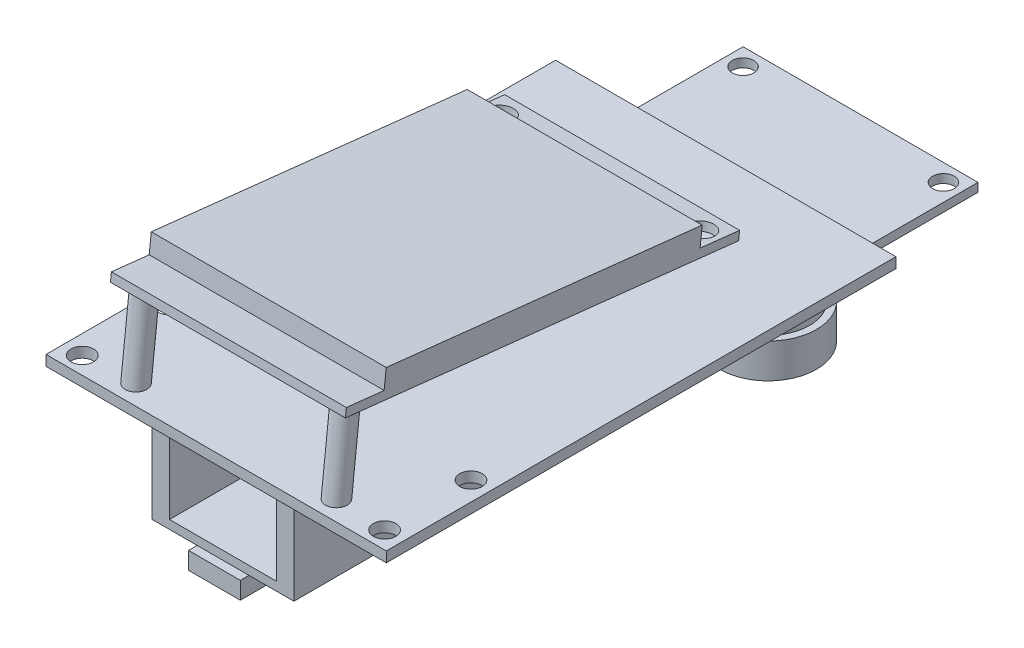
from build123d import *

# Parameters (mm, degrees)
SKETCH1_W                       = 50.038
SKETCH1_H                       = 74.93
SKETCH1_R                       = 1.651
BOSS_EXTRUDE1_DEPTH             = 1.524
BOSS_EXTRUDE2_DEPTH             = 17.272
SKETCH3_R                       = 1.778
CUT_EXTRUDE2_DEPTH              = 1.27
BOSS_EXTRUDE3_REACH             = 48.946
SKETCH4_R                       = 0.254
SKETCH4_R_2                     = 1.5875
SKETCH5_W                       = 2.54
SKETCH5_H                       = 50.8
BOSS_EXTRUDE4_DEPTH             = 11.43
SKETCH6_W                       = 20.828
SKETCH6_H                       = 50.8
BOSS_EXTRUDE5_DEPTH             = 1.27
SKETCH7_R                       = 0.889
BOSS_EXTRUDE6_DEPTH             = 0.635
BOSS_EXTRUDE6_TAPER             = 45
SKETCH7_3_W                     = 7.62
SKETCH7_3_H                     = 6.35
BOSS_EXTRUDE7_DEPTH             = 2.54
BOSS_EXTRUDE8_START             = 2.794
SKETCH9_W                       = 34.544
SKETCH9_H                       = 35.052
BOSS_EXTRUDE8_DEPTH             = 1.27
SKETCH10_W                      = 16.51
SKETCH10_H                      = 16.51
BOSS_EXTRUDE9_DEPTH             = 7.62
SKETCH11_R                      = 7.366
BOSS_EXTRUDE10_DEPTH            = 5.588
SKETCH12_R                      = 6.096
BOSS_EXTRUDE11_DEPTH            = 2.54
SKETCH13_R                      = 7.112
BOSS_EXTRUDE12_DEPTH            = 5.08
SKETCH15_R                      = 1.5875
CUT_EXTRUDE3_DEPTH              = 1.27
SKETCH16_R                      = 0.889
BOSS_EXTRUDE13_DEPTH            = 4.064
SKETCH16_2_R                    = 0.889
BOSS_EXTRUDE14_DEPTH            = 0.635
BOSS_EXTRUDE14_DRAFT            = 45
BOSS_EXTRUDE14_PROFILE_2_DEPTH  = 0.635
BOSS_EXTRUDE14_PROFILE_2_DRAFT  = 45
BOSS_EXTRUDE14_PROFILE_3_DEPTH  = 0.635
BOSS_EXTRUDE14_PROFILE_3_DRAFT  = 45
BOSS_EXTRUDE14_PROFILE_4_DEPTH  = 0.635
BOSS_EXTRUDE14_PROFILE_4_DRAFT  = 45
BOSS_EXTRUDE14_PROFILE_5_DEPTH  = 0.635
BOSS_EXTRUDE14_PROFILE_5_DRAFT  = 45
BOSS_EXTRUDE14_PROFILE_6_DEPTH  = 0.635
BOSS_EXTRUDE14_PROFILE_6_DRAFT  = 45
BOSS_EXTRUDE14_PROFILE_7_DEPTH  = 0.635
BOSS_EXTRUDE14_PROFILE_7_DRAFT  = 45
BOSS_EXTRUDE14_PROFILE_8_DEPTH  = 0.635
BOSS_EXTRUDE14_PROFILE_8_DRAFT  = 45
BOSS_EXTRUDE14_PROFILE_9_DEPTH  = 0.635
BOSS_EXTRUDE14_PROFILE_9_DRAFT  = 45
BOSS_EXTRUDE14_PROFILE_10_DEPTH = 0.635
BOSS_EXTRUDE14_PROFILE_10_DRAFT = 45
BOSS_EXTRUDE14_PROFILE_11_DEPTH = 0.635
BOSS_EXTRUDE14_PROFILE_11_DRAFT = 45
BOSS_EXTRUDE14_PROFILE_12_DEPTH = 0.635
BOSS_EXTRUDE14_PROFILE_12_DRAFT = 45
BOSS_EXTRUDE14_PROFILE_13_DEPTH = 0.635
BOSS_EXTRUDE14_PROFILE_13_DRAFT = 45
BOSS_EXTRUDE14_PROFILE_14_DEPTH = 0.635
BOSS_EXTRUDE14_PROFILE_14_DRAFT = 45
BOSS_EXTRUDE14_PROFILE_15_DEPTH = 0.635
BOSS_EXTRUDE14_PROFILE_15_DRAFT = 45
BOSS_EXTRUDE14_PROFILE_16_DEPTH = 0.635
BOSS_EXTRUDE14_PROFILE_16_DRAFT = 45
BOSS_EXTRUDE14_PROFILE_17_DEPTH = 0.635
BOSS_EXTRUDE14_PROFILE_17_DRAFT = 45
BOSS_EXTRUDE14_PROFILE_18_DEPTH = 0.635
BOSS_EXTRUDE14_PROFILE_18_DRAFT = 45
BOSS_EXTRUDE14_PROFILE_19_DEPTH = 0.635
BOSS_EXTRUDE14_PROFILE_19_DRAFT = 45
BOSS_EXTRUDE14_PROFILE_20_DEPTH = 0.635
BOSS_EXTRUDE14_PROFILE_20_DRAFT = 45


with BuildPart() as part:
    # Sketch1 → Boss-Extrude1 (new body)
    with BuildSketch(Plane(origin=(0, 0, 0), x_dir=(1, 0, 0), z_dir=(0, 1, 0))):
        Rectangle(SKETCH1_W, SKETCH1_H)
        with Locations(Location((22.225, -34.925, 0), (0, 0, 90))):
            Circle(SKETCH1_R, mode=Mode.SUBTRACT)
        with Locations(Location((22.225, -22.225, 0), (0, 0, 90))):
            Circle(SKETCH1_R, mode=Mode.SUBTRACT)
        with Locations(Location((-22.225, -34.925, 0), (0, 0, 90))):
            Circle(SKETCH1_R, mode=Mode.SUBTRACT)
        with Locations(Location((-22.225, -22.225, 0), (0, 0, 90))):
            Circle(SKETCH1_R, mode=Mode.SUBTRACT)
    extrude(amount=BOSS_EXTRUDE1_DEPTH)



with BuildPart() as body_2:
    # Sketch2 → Boss-Extrude2 (new, symmetric)
    with BuildSketch(Plane(origin=(0, 0, 0), x_dir=(0, 0, -1), z_dir=(1, 0, 0))):
        Polygon((-30.038744463, 14.368365618), (16.417917282, 9.266182212), (16.722939116, 12.043482643), (-29.733722629, 17.145666049), align=None)
        Polygon((22.086353712, 7.366), (22.225, 8.628409287), (-35.593345324, 14.978409287), (-35.731991612, 13.716), align=None)
    extrude(amount=BOSS_EXTRUDE2_DEPTH, both=True)

    # Sketch3 → Cut-Extrude2 (cut)
    with BuildSketch(Plane(origin=(0, 10.937382697, -1.201217014), x_dir=(1, 0, 0), z_dir=(0, 0.9940230602749727, -0.1091703056768559))):
        with Locations(Location((14.732, 18.102196435, 0), (0, 0, 270))):
            Circle(SKETCH3_R)
        with Locations(Location((-14.732, 18.102196435, 0), (0, 0, 270))):
            Circle(SKETCH3_R)
    extrude(amount=-CUT_EXTRUDE2_DEPTH, mode=Mode.SUBTRACT)


with BuildPart() as part_1:
    add(part.part)

    add(body_2.part)  # Boss-Extrude3 merges body 2
    # Boss-Extrude3: up to this plane
    boss_extrude3_end = Plane(origin=(0, 1.524, 0), z_dir=(0, 1, 0))
    # Sketch4 → Boss-Extrude3 (add, up to the surface)
    with BuildSketch(Plane(origin=(0, 9.67497341, -1.062570726), x_dir=(1, 0, 0), z_dir=(0, -0.9940230602749727, 0.1091703056768559)), mode=Mode.PRIVATE) as boss_extrude3_sk1:
        with Locations(Location((-0.889, -19.372196435, 0), (0, 0, 270))):
            Circle(SKETCH4_R)
    boss_extrude3_tool1 = split(extrude(boss_extrude3_sk1.sketch, amount=BOSS_EXTRUDE3_REACH, mode=Mode.PRIVATE), bisect_by=boss_extrude3_end, keep=Keep.BOTH, mode=Mode.PRIVATE)
    add(boss_extrude3_tool1.solids().sort_by_distance((-0.889, 7.560105, -20.318981))[0])
    # Sketch4 → Boss-Extrude3 (add, up to the surface)
    with BuildSketch(Plane(origin=(0, 9.67497341, -1.062570726), x_dir=(1, 0, 0), z_dir=(0, -0.9940230602749727, 0.1091703056768559)), mode=Mode.PRIVATE) as boss_extrude3_sk2:
        with Locations(Location((0.889, -19.372196435, 0), (0, 0, 270))):
            Circle(SKETCH4_R)
    boss_extrude3_tool2 = split(extrude(boss_extrude3_sk2.sketch, amount=BOSS_EXTRUDE3_REACH, mode=Mode.PRIVATE), bisect_by=boss_extrude3_end, keep=Keep.BOTH, mode=Mode.PRIVATE)
    add(boss_extrude3_tool2.solids().sort_by_distance((0.889, 7.560105, -20.318981))[0])
    # Sketch4 → Boss-Extrude3 (add, up to the surface)
    with BuildSketch(Plane(origin=(0, 9.67497341, -1.062570726), x_dir=(1, 0, 0), z_dir=(0, -0.9940230602749727, 0.1091703056768559)), mode=Mode.PRIVATE) as boss_extrude3_sk3:
        with Locations(Location((-2.667, -19.372196435, 0), (0, 0, 270))):
            Circle(SKETCH4_R)
    boss_extrude3_tool3 = split(extrude(boss_extrude3_sk3.sketch, amount=BOSS_EXTRUDE3_REACH, mode=Mode.PRIVATE), bisect_by=boss_extrude3_end, keep=Keep.BOTH, mode=Mode.PRIVATE)
    add(boss_extrude3_tool3.solids().sort_by_distance((-2.667, 7.560105, -20.318981))[0])
    # Sketch4 → Boss-Extrude3 (add, up to the surface)
    with BuildSketch(Plane(origin=(0, 9.67497341, -1.062570726), x_dir=(1, 0, 0), z_dir=(0, -0.9940230602749727, 0.1091703056768559)), mode=Mode.PRIVATE) as boss_extrude3_sk4:
        with Locations(Location((-4.445, -19.372196435, 0), (0, 0, 270))):
            Circle(SKETCH4_R)
    boss_extrude3_tool4 = split(extrude(boss_extrude3_sk4.sketch, amount=BOSS_EXTRUDE3_REACH, mode=Mode.PRIVATE), bisect_by=boss_extrude3_end, keep=Keep.BOTH, mode=Mode.PRIVATE)
    add(boss_extrude3_tool4.solids().sort_by_distance((-4.445, 7.560105, -20.318981))[0])
    # Sketch4 → Boss-Extrude3 (add, up to the surface)
    with BuildSketch(Plane(origin=(0, 9.67497341, -1.062570726), x_dir=(1, 0, 0), z_dir=(0, -0.9940230602749727, 0.1091703056768559)), mode=Mode.PRIVATE) as boss_extrude3_sk5:
        with Locations(Location((-6.223, -19.372196435, 0), (0, 0, 270))):
            Circle(SKETCH4_R)
    boss_extrude3_tool5 = split(extrude(boss_extrude3_sk5.sketch, amount=BOSS_EXTRUDE3_REACH, mode=Mode.PRIVATE), bisect_by=boss_extrude3_end, keep=Keep.BOTH, mode=Mode.PRIVATE)
    add(boss_extrude3_tool5.solids().sort_by_distance((-6.223, 7.560105, -20.318981))[0])
    # Sketch4 → Boss-Extrude3 (add, up to the surface)
    with BuildSketch(Plane(origin=(0, 9.67497341, -1.062570726), x_dir=(1, 0, 0), z_dir=(0, -0.9940230602749727, 0.1091703056768559)), mode=Mode.PRIVATE) as boss_extrude3_sk6:
        with Locations(Location((2.667, -19.372196435, 0), (0, 0, 270))):
            Circle(SKETCH4_R)
    boss_extrude3_tool6 = split(extrude(boss_extrude3_sk6.sketch, amount=BOSS_EXTRUDE3_REACH, mode=Mode.PRIVATE), bisect_by=boss_extrude3_end, keep=Keep.BOTH, mode=Mode.PRIVATE)
    add(boss_extrude3_tool6.solids().sort_by_distance((2.667, 7.560105, -20.318981))[0])
    # Sketch4 → Boss-Extrude3 (add, up to the surface)
    with BuildSketch(Plane(origin=(0, 9.67497341, -1.062570726), x_dir=(1, 0, 0), z_dir=(0, -0.9940230602749727, 0.1091703056768559)), mode=Mode.PRIVATE) as boss_extrude3_sk7:
        with Locations(Location((4.445, -19.372196435, 0), (0, 0, 270))):
            Circle(SKETCH4_R)
    boss_extrude3_tool7 = split(extrude(boss_extrude3_sk7.sketch, amount=BOSS_EXTRUDE3_REACH, mode=Mode.PRIVATE), bisect_by=boss_extrude3_end, keep=Keep.BOTH, mode=Mode.PRIVATE)
    add(boss_extrude3_tool7.solids().sort_by_distance((4.445, 7.560105, -20.318981))[0])
    # Sketch4 → Boss-Extrude3 (add, up to the surface)
    with BuildSketch(Plane(origin=(0, 9.67497341, -1.062570726), x_dir=(1, 0, 0), z_dir=(0, -0.9940230602749727, 0.1091703056768559)), mode=Mode.PRIVATE) as boss_extrude3_sk8:
        with Locations(Location((6.223, -19.372196435, 0), (0, 0, 270))):
            Circle(SKETCH4_R)
    boss_extrude3_tool8 = split(extrude(boss_extrude3_sk8.sketch, amount=BOSS_EXTRUDE3_REACH, mode=Mode.PRIVATE), bisect_by=boss_extrude3_end, keep=Keep.BOTH, mode=Mode.PRIVATE)
    add(boss_extrude3_tool8.solids().sort_by_distance((6.223, 7.560105, -20.318981))[0])
    # Sketch4 → Boss-Extrude3 (add, up to the surface)
    with BuildSketch(Plane(origin=(0, 9.67497341, -1.062570726), x_dir=(1, 0, 0), z_dir=(0, -0.9940230602749727, 0.1091703056768559)), mode=Mode.PRIVATE) as boss_extrude3_sk9:
        with Locations(Location((14.732, 34.475803565, 0), (0, 0, 270))):
            Circle(SKETCH4_R_2)
    boss_extrude3_tool9 = split(extrude(boss_extrude3_sk9.sketch, amount=BOSS_EXTRUDE3_REACH, mode=Mode.PRIVATE), bisect_by=boss_extrude3_end, keep=Keep.BOTH, mode=Mode.PRIVATE)
    add(boss_extrude3_tool9.solids().sort_by_distance((14.732, 13.438707, 33.207173))[0])
    # Sketch4 → Boss-Extrude3 (add, up to the surface)
    with BuildSketch(Plane(origin=(0, 9.67497341, -1.062570726), x_dir=(1, 0, 0), z_dir=(0, -0.9940230602749727, 0.1091703056768559)), mode=Mode.PRIVATE) as boss_extrude3_sk10:
        with Locations(Location((-14.732, 34.475803565, 0), (0, 0, 90))):
            Circle(SKETCH4_R_2)
    boss_extrude3_tool10 = split(extrude(boss_extrude3_sk10.sketch, amount=BOSS_EXTRUDE3_REACH, mode=Mode.PRIVATE), bisect_by=boss_extrude3_end, keep=Keep.BOTH, mode=Mode.PRIVATE)
    add(boss_extrude3_tool10.solids().sort_by_distance((-14.732, 13.438707, 33.207173))[0])

    # Sketch5 → Boss-Extrude4 (add)
    with BuildSketch(Plane.XZ):
        with Locations((9.144, 11.049)):
            Rectangle(SKETCH5_W, SKETCH5_H)
        with Locations((-9.144, 11.049)):
            Rectangle(SKETCH5_W, SKETCH5_H)
    extrude(amount=BOSS_EXTRUDE4_DEPTH)

    # Sketch6 → Boss-Extrude5 (add)
    with BuildSketch(Plane.XZ.offset(11.43)):
        with Locations((0, 11.049)):
            Rectangle(SKETCH6_W, SKETCH6_H)
    extrude(amount=BOSS_EXTRUDE5_DEPTH)

    # Sketch7 → Boss-Extrude6 (add)
    with BuildSketch(Plane.XZ.offset(12.7)):
        with Locations((-9.144, 32.639)):
            Circle(SKETCH7_R)
        with Locations((-9.144, 30.099)):
            Circle(SKETCH7_R)
        with Locations((-9.144, 25.019)):
            Circle(SKETCH7_R)
        with Locations((-9.144, 22.479)):
            Circle(SKETCH7_R)
        with Locations((-9.144, 19.939)):
            Circle(SKETCH7_R)
        with Locations((-9.144, 14.859)):
            Circle(SKETCH7_R)
        with Locations((-9.144, 4.699)):
            Circle(SKETCH7_R)
        with Locations((-9.144, 2.159)):
            Circle(SKETCH7_R)
        with Locations((-9.144, -8.001)):
            Circle(SKETCH7_R)
        with Locations((-9.144, -10.541)):
            Circle(SKETCH7_R)
        with Locations((-9.144, -13.081)):
            Circle(SKETCH7_R)
        with Locations((9.144, -10.541)):
            Circle(SKETCH7_R)
        with Locations((9.144, -2.921)):
            Circle(SKETCH7_R)
        with Locations((9.144, 2.159)):
            Circle(SKETCH7_R)
        with Locations((9.144, 4.699)):
            Circle(SKETCH7_R)
        with Locations((9.144, 7.239)):
            Circle(SKETCH7_R)
        with Locations((9.144, 17.399)):
            Circle(SKETCH7_R)
        with Locations((9.144, 19.939)):
            Circle(SKETCH7_R)
        with Locations((9.144, 35.179)):
            Circle(SKETCH7_R)
        with Locations((-9.144, 35.179)):
            Circle(SKETCH7_R)
        with Locations((-9.144, 27.559)):
            Circle(SKETCH7_R)
        with Locations((-9.144, 17.399)):
            Circle(SKETCH7_R)
        with Locations((-9.144, 12.319)):
            Circle(SKETCH7_R)
        with Locations((-9.144, 9.779)):
            Circle(SKETCH7_R)
        with Locations((-9.144, 7.239)):
            Circle(SKETCH7_R)
        with Locations((-9.144, -0.381)):
            Circle(SKETCH7_R)
        with Locations((-9.144, -2.921)):
            Circle(SKETCH7_R)
        with Locations((-9.144, -5.461)):
            Circle(SKETCH7_R)
        with Locations((9.144, -13.081)):
            Circle(SKETCH7_R)
        with Locations((9.144, -8.001)):
            Circle(SKETCH7_R)
        with Locations((9.144, -5.461)):
            Circle(SKETCH7_R)
        with Locations((9.144, -0.381)):
            Circle(SKETCH7_R)
        with Locations((9.144, 9.779)):
            Circle(SKETCH7_R)
        with Locations((9.144, 12.319)):
            Circle(SKETCH7_R)
        with Locations((9.144, 14.859)):
            Circle(SKETCH7_R)
        with Locations((9.144, 22.479)):
            Circle(SKETCH7_R)
        with Locations((9.144, 25.019)):
            Circle(SKETCH7_R)
        with Locations((9.144, 27.559)):
            Circle(SKETCH7_R)
        with Locations((9.144, 30.099)):
            Circle(SKETCH7_R)
        with Locations((9.144, 32.639)):
            Circle(SKETCH7_R)
    extrude(amount=BOSS_EXTRUDE6_DEPTH, taper=BOSS_EXTRUDE6_TAPER)

    # Sketch7_3 → Boss-Extrude7 (add)
    with BuildSketch(Plane.XZ.offset(12.7)):
        with Locations((0, 34.544)):
            Rectangle(SKETCH7_3_W, SKETCH7_3_H)
    extrude(amount=BOSS_EXTRUDE7_DEPTH)


with BuildPart() as body_2_2:
    # Sketch9 → Boss-Extrude8 (new body)
    with BuildSketch(Plane.XZ.offset(BOSS_EXTRUDE8_START)):
        with Locations((0, -39.751)):
            Rectangle(SKETCH9_W, SKETCH9_H)
    extrude(amount=BOSS_EXTRUDE8_DEPTH)

    # Sketch10 → Boss-Extrude9 (add)
    with BuildSketch(Plane.XZ.offset(4.064)):
        with BuildLine():
            Line((-9.779, -45.72), (-8.255, -45.72))
            Line((-8.255, -45.72), (-8.255, -41.656))
            Line((-8.255, -41.656), (-9.779, -41.656))
            ThreePointArc((-9.779, -41.656), (-11.811, -43.688), (-9.779, -45.72))
        make_face()
        with Locations((0, -43.688)):
            Rectangle(SKETCH10_W, SKETCH10_H)
        with BuildLine():
            Line((8.255, -41.656), (8.255, -45.72))
            Line((8.255, -45.72), (9.779, -45.72))
            ThreePointArc((9.779, -45.72), (11.811, -43.688), (9.779, -41.656))
            Line((9.779, -41.656), (8.255, -41.656))
        make_face()
    extrude(amount=BOSS_EXTRUDE9_DEPTH)

    # Sketch11 → Boss-Extrude10 (add)
    with BuildSketch(Plane.XZ.offset(11.684)):
        with Locations(Location((0, -43.688, 0), (0, 0, 270))):
            Circle(SKETCH11_R)
    extrude(amount=BOSS_EXTRUDE10_DEPTH)

    # Sketch12 → Boss-Extrude11 (add)
    with BuildSketch(Plane.XZ.offset(17.272)):
        with Locations(Location((0, -43.688, 0), (0, 0, 270))):
            Circle(SKETCH12_R)
    extrude(amount=BOSS_EXTRUDE11_DEPTH)

    # Sketch13 → Boss-Extrude12 (add)
    with BuildSketch(Plane.XZ.offset(19.812)):
        with Locations(Location((0, -43.688, 0), (0, 0, 270))):
            Circle(SKETCH13_R)
    extrude(amount=BOSS_EXTRUDE12_DEPTH)

    # Sketch14 → Cut-Revolve1 (revolve, cut)
    with BuildSketch(Plane(origin=(0, 0, 0), x_dir=(0, 0, -1), z_dir=(1, 0, 0)), mode=Mode.PRIVATE) as cut_revolve1_sk:
        with BuildLine():
            Line((50.54454245, -24.892), (49.444690187, -24.257))
            add(Edge.make_bspline(
                [(43.688, -24.765), (46.588759362, -24.765), (49.444690187, -24.257)],
                knots=[0, 0, 0, 1, 1, 1], degree=2))
            Line((43.688, -24.765), (43.688, -27.265018721))
            Line((43.688, -27.265018721), (50.54454245, -27.265018721))
            Line((50.54454245, -27.265018721), (50.54454245, -24.892))
        make_face()
    revolve(cut_revolve1_sk.sketch.rotate(Axis((0, -19.812, -43.688), (0, -1, 0)), 180), axis=Axis((0, -19.812, -43.688), (0, -1, 0)), mode=Mode.SUBTRACT)

    # Sketch15 → Cut-Extrude3 (cut)
    with BuildSketch(Plane.XZ.offset(4.064)):
        with Locations(Location((-14.732, -24.765, 0), (0, 0, 270))):
            Circle(SKETCH15_R)
        with Locations(Location((14.732, -24.765, 0), (0, 0, 90))):
            Circle(SKETCH15_R)
        with Locations(Location((14.732, -54.737, 0), (0, 0, 270))):
            Circle(SKETCH15_R)
        with Locations(Location((-14.732, -54.737, 0), (0, 0, 90))):
            Circle(SKETCH15_R)
    extrude(amount=-CUT_EXTRUDE3_DEPTH, mode=Mode.SUBTRACT)

    # Sketch16 → Boss-Extrude13 (add)
    with BuildSketch(Plane.XZ.offset(4.064)):
        with Locations(Location((11.43, -27.305, 0), (0, 0, 90))):
            Circle(SKETCH16_R)
        with Locations(Location((8.89, -27.305, 0), (0, 0, 90))):
            Circle(SKETCH16_R)
        with Locations(Location((6.35, -27.305, 0), (0, 0, 90))):
            Circle(SKETCH16_R)
        with Locations(Location((3.81, -27.305, 0), (0, 0, 90))):
            Circle(SKETCH16_R)
        with Locations(Location((1.27, -27.305, 0), (0, 0, 90))):
            Circle(SKETCH16_R)
        with Locations(Location((-1.27, -27.305, 0), (0, 0, 90))):
            Circle(SKETCH16_R)
        with Locations(Location((-3.81, -27.305, 0), (0, 0, 90))):
            Circle(SKETCH16_R)
        with Locations(Location((-6.35, -27.305, 0), (0, 0, 90))):
            Circle(SKETCH16_R)
        with Locations(Location((-8.89, -27.305, 0), (0, 0, 90))):
            Circle(SKETCH16_R)
        with Locations(Location((-11.43, -27.305, 0), (0, 0, 90))):
            Circle(SKETCH16_R)
        with Locations(Location((8.89, -29.845, 0), (0, 0, 90))):
            Circle(SKETCH16_R)
        with Locations(Location((6.35, -29.845, 0), (0, 0, 90))):
            Circle(SKETCH16_R)
        with Locations(Location((3.81, -29.845, 0), (0, 0, 90))):
            Circle(SKETCH16_R)
        with Locations(Location((1.27, -29.845, 0), (0, 0, 90))):
            Circle(SKETCH16_R)
        with Locations(Location((-1.27, -29.845, 0), (0, 0, 90))):
            Circle(SKETCH16_R)
        with Locations(Location((-3.81, -29.845, 0), (0, 0, 90))):
            Circle(SKETCH16_R)
        with Locations(Location((-6.35, -29.845, 0), (0, 0, 90))):
            Circle(SKETCH16_R)
        with Locations(Location((-8.89, -29.845, 0), (0, 0, 90))):
            Circle(SKETCH16_R)
        with Locations(Location((-11.43, -29.845, 0), (0, 0, 90))):
            Circle(SKETCH16_R)
        with Locations(Location((11.43, -29.845, 0), (0, 0, 90))):
            Circle(SKETCH16_R)
    extrude(amount=-BOSS_EXTRUDE13_DEPTH)


with BuildPart() as boss_extrude14_tool:
    # Sketch16_2 → Boss-Extrude14 (with draft: the straight prism first)
    with BuildSketch(Plane.XZ.offset(4.064)):
        with Locations(Location((-11.43, -29.845, 0), (0, 0, 90))):
            Circle(SKETCH16_2_R)
    extrude(amount=BOSS_EXTRUDE14_DEPTH)
    # Boss-Extrude14: the draft: its side faces are tilted about the plane it starts from
    boss_extrude14_sides = [boss_extrude14_tool.faces().sort_by_distance(p)[0] for p in [
        (-11.43, -4.3815, -30.734),
    ]]
    draft(boss_extrude14_sides, Plane.XZ.offset(4.064), BOSS_EXTRUDE14_DRAFT)


with BuildPart() as part_2:
    add(part_1.part)

    # Boss-Extrude14: add boss_extrude14_tool
    add(boss_extrude14_tool.part)

    add(body_2_2.part)  # Boss-Extrude14 merges body 2 2


with BuildPart() as boss_extrude14_profile_2_tool:
    # Sketch16_2 → Boss-Extrude14 profile 2 (with draft: the straight prism first)
    with BuildSketch(Plane.XZ.offset(4.064)):
        with Locations(Location((-8.89, -29.845, 0), (0, 0, 90))):
            Circle(SKETCH16_2_R)
    extrude(amount=BOSS_EXTRUDE14_PROFILE_2_DEPTH)
    # Boss-Extrude14 profile 2: the draft: its side faces are tilted about the plane it starts from
    boss_extrude14_profile_2_sides = [boss_extrude14_profile_2_tool.faces().sort_by_distance(p)[0] for p in [
        (-8.89, -4.3815, -30.734),
    ]]
    draft(boss_extrude14_profile_2_sides, Plane.XZ.offset(4.064), BOSS_EXTRUDE14_PROFILE_2_DRAFT)


with BuildPart() as part_3:
    add(part_2.part)

    # Boss-Extrude14 profile 2: add boss_extrude14_profile_2_tool
    add(boss_extrude14_profile_2_tool.part)


with BuildPart() as boss_extrude14_profile_3_tool:
    # Sketch16_2 → Boss-Extrude14 profile 3 (with draft: the straight prism first)
    with BuildSketch(Plane.XZ.offset(4.064)):
        with Locations(Location((-8.89, -27.305, 0), (0, 0, 90))):
            Circle(SKETCH16_2_R)
    extrude(amount=BOSS_EXTRUDE14_PROFILE_3_DEPTH)
    # Boss-Extrude14 profile 3: the draft: its side faces are tilted about the plane it starts from
    boss_extrude14_profile_3_sides = [boss_extrude14_profile_3_tool.faces().sort_by_distance(p)[0] for p in [
        (-8.89, -4.3815, -28.194),
    ]]
    draft(boss_extrude14_profile_3_sides, Plane.XZ.offset(4.064), BOSS_EXTRUDE14_PROFILE_3_DRAFT)


with BuildPart() as part_4:
    add(part_3.part)

    # Boss-Extrude14 profile 3: add boss_extrude14_profile_3_tool
    add(boss_extrude14_profile_3_tool.part)


with BuildPart() as boss_extrude14_profile_4_tool:
    # Sketch16_2 → Boss-Extrude14 profile 4 (with draft: the straight prism first)
    with BuildSketch(Plane.XZ.offset(4.064)):
        with Locations(Location((-6.35, -27.305, 0), (0, 0, 90))):
            Circle(SKETCH16_2_R)
    extrude(amount=BOSS_EXTRUDE14_PROFILE_4_DEPTH)
    # Boss-Extrude14 profile 4: the draft: its side faces are tilted about the plane it starts from
    boss_extrude14_profile_4_sides = [boss_extrude14_profile_4_tool.faces().sort_by_distance(p)[0] for p in [
        (-6.35, -4.3815, -28.194),
    ]]
    draft(boss_extrude14_profile_4_sides, Plane.XZ.offset(4.064), BOSS_EXTRUDE14_PROFILE_4_DRAFT)


with BuildPart() as part_5:
    add(part_4.part)

    # Boss-Extrude14 profile 4: add boss_extrude14_profile_4_tool
    add(boss_extrude14_profile_4_tool.part)


with BuildPart() as boss_extrude14_profile_5_tool:
    # Sketch16_2 → Boss-Extrude14 profile 5 (with draft: the straight prism first)
    with BuildSketch(Plane.XZ.offset(4.064)):
        with Locations(Location((-6.35, -29.845, 0), (0, 0, 90))):
            Circle(SKETCH16_2_R)
    extrude(amount=BOSS_EXTRUDE14_PROFILE_5_DEPTH)
    # Boss-Extrude14 profile 5: the draft: its side faces are tilted about the plane it starts from
    boss_extrude14_profile_5_sides = [boss_extrude14_profile_5_tool.faces().sort_by_distance(p)[0] for p in [
        (-6.35, -4.3815, -30.734),
    ]]
    draft(boss_extrude14_profile_5_sides, Plane.XZ.offset(4.064), BOSS_EXTRUDE14_PROFILE_5_DRAFT)


with BuildPart() as part_6:
    add(part_5.part)

    # Boss-Extrude14 profile 5: add boss_extrude14_profile_5_tool
    add(boss_extrude14_profile_5_tool.part)


with BuildPart() as boss_extrude14_profile_6_tool:
    # Sketch16_2 → Boss-Extrude14 profile 6 (with draft: the straight prism first)
    with BuildSketch(Plane.XZ.offset(4.064)):
        with Locations(Location((-3.81, -29.845, 0), (0, 0, 90))):
            Circle(SKETCH16_2_R)
    extrude(amount=BOSS_EXTRUDE14_PROFILE_6_DEPTH)
    # Boss-Extrude14 profile 6: the draft: its side faces are tilted about the plane it starts from
    boss_extrude14_profile_6_sides = [boss_extrude14_profile_6_tool.faces().sort_by_distance(p)[0] for p in [
        (-3.81, -4.3815, -30.734),
    ]]
    draft(boss_extrude14_profile_6_sides, Plane.XZ.offset(4.064), BOSS_EXTRUDE14_PROFILE_6_DRAFT)


with BuildPart() as part_7:
    add(part_6.part)

    # Boss-Extrude14 profile 6: add boss_extrude14_profile_6_tool
    add(boss_extrude14_profile_6_tool.part)


with BuildPart() as boss_extrude14_profile_7_tool:
    # Sketch16_2 → Boss-Extrude14 profile 7 (with draft: the straight prism first)
    with BuildSketch(Plane.XZ.offset(4.064)):
        with Locations(Location((-3.81, -27.305, 0), (0, 0, 90))):
            Circle(SKETCH16_2_R)
    extrude(amount=BOSS_EXTRUDE14_PROFILE_7_DEPTH)
    # Boss-Extrude14 profile 7: the draft: its side faces are tilted about the plane it starts from
    boss_extrude14_profile_7_sides = [boss_extrude14_profile_7_tool.faces().sort_by_distance(p)[0] for p in [
        (-3.81, -4.3815, -28.194),
    ]]
    draft(boss_extrude14_profile_7_sides, Plane.XZ.offset(4.064), BOSS_EXTRUDE14_PROFILE_7_DRAFT)


with BuildPart() as part_8:
    add(part_7.part)

    # Boss-Extrude14 profile 7: add boss_extrude14_profile_7_tool
    add(boss_extrude14_profile_7_tool.part)


with BuildPart() as boss_extrude14_profile_8_tool:
    # Sketch16_2 → Boss-Extrude14 profile 8 (with draft: the straight prism first)
    with BuildSketch(Plane.XZ.offset(4.064)):
        with Locations(Location((-1.27, -27.305, 0), (0, 0, 90))):
            Circle(SKETCH16_2_R)
    extrude(amount=BOSS_EXTRUDE14_PROFILE_8_DEPTH)
    # Boss-Extrude14 profile 8: the draft: its side faces are tilted about the plane it starts from
    boss_extrude14_profile_8_sides = [boss_extrude14_profile_8_tool.faces().sort_by_distance(p)[0] for p in [
        (-1.27, -4.3815, -28.194),
    ]]
    draft(boss_extrude14_profile_8_sides, Plane.XZ.offset(4.064), BOSS_EXTRUDE14_PROFILE_8_DRAFT)


with BuildPart() as part_9:
    add(part_8.part)

    # Boss-Extrude14 profile 8: add boss_extrude14_profile_8_tool
    add(boss_extrude14_profile_8_tool.part)


with BuildPart() as boss_extrude14_profile_9_tool:
    # Sketch16_2 → Boss-Extrude14 profile 9 (with draft: the straight prism first)
    with BuildSketch(Plane.XZ.offset(4.064)):
        with Locations(Location((-1.27, -29.845, 0), (0, 0, 90))):
            Circle(SKETCH16_2_R)
    extrude(amount=BOSS_EXTRUDE14_PROFILE_9_DEPTH)
    # Boss-Extrude14 profile 9: the draft: its side faces are tilted about the plane it starts from
    boss_extrude14_profile_9_sides = [boss_extrude14_profile_9_tool.faces().sort_by_distance(p)[0] for p in [
        (-1.27, -4.3815, -30.734),
    ]]
    draft(boss_extrude14_profile_9_sides, Plane.XZ.offset(4.064), BOSS_EXTRUDE14_PROFILE_9_DRAFT)


with BuildPart() as part_10:
    add(part_9.part)

    # Boss-Extrude14 profile 9: add boss_extrude14_profile_9_tool
    add(boss_extrude14_profile_9_tool.part)


with BuildPart() as boss_extrude14_profile_10_tool:
    # Sketch16_2 → Boss-Extrude14 profile 10 (with draft: the straight prism first)
    with BuildSketch(Plane.XZ.offset(4.064)):
        with Locations(Location((1.27, -29.845, 0), (0, 0, 90))):
            Circle(SKETCH16_2_R)
    extrude(amount=BOSS_EXTRUDE14_PROFILE_10_DEPTH)
    # Boss-Extrude14 profile 10: the draft: its side faces are tilted about the plane it starts from
    boss_extrude14_profile_10_sides = [boss_extrude14_profile_10_tool.faces().sort_by_distance(p)[0] for p in [
        (1.27, -4.3815, -30.734),
    ]]
    draft(boss_extrude14_profile_10_sides, Plane.XZ.offset(4.064), BOSS_EXTRUDE14_PROFILE_10_DRAFT)


with BuildPart() as part_11:
    add(part_10.part)

    # Boss-Extrude14 profile 10: add boss_extrude14_profile_10_tool
    add(boss_extrude14_profile_10_tool.part)


with BuildPart() as boss_extrude14_profile_11_tool:
    # Sketch16_2 → Boss-Extrude14 profile 11 (with draft: the straight prism first)
    with BuildSketch(Plane.XZ.offset(4.064)):
        with Locations(Location((1.27, -27.305, 0), (0, 0, 90))):
            Circle(SKETCH16_2_R)
    extrude(amount=BOSS_EXTRUDE14_PROFILE_11_DEPTH)
    # Boss-Extrude14 profile 11: the draft: its side faces are tilted about the plane it starts from
    boss_extrude14_profile_11_sides = [boss_extrude14_profile_11_tool.faces().sort_by_distance(p)[0] for p in [
        (1.27, -4.3815, -28.194),
    ]]
    draft(boss_extrude14_profile_11_sides, Plane.XZ.offset(4.064), BOSS_EXTRUDE14_PROFILE_11_DRAFT)


with BuildPart() as part_12:
    add(part_11.part)

    # Boss-Extrude14 profile 11: add boss_extrude14_profile_11_tool
    add(boss_extrude14_profile_11_tool.part)


with BuildPart() as boss_extrude14_profile_12_tool:
    # Sketch16_2 → Boss-Extrude14 profile 12 (with draft: the straight prism first)
    with BuildSketch(Plane.XZ.offset(4.064)):
        with Locations(Location((3.81, -29.845, 0), (0, 0, 90))):
            Circle(SKETCH16_2_R)
    extrude(amount=BOSS_EXTRUDE14_PROFILE_12_DEPTH)
    # Boss-Extrude14 profile 12: the draft: its side faces are tilted about the plane it starts from
    boss_extrude14_profile_12_sides = [boss_extrude14_profile_12_tool.faces().sort_by_distance(p)[0] for p in [
        (3.81, -4.3815, -30.734),
    ]]
    draft(boss_extrude14_profile_12_sides, Plane.XZ.offset(4.064), BOSS_EXTRUDE14_PROFILE_12_DRAFT)


with BuildPart() as part_13:
    add(part_12.part)

    # Boss-Extrude14 profile 12: add boss_extrude14_profile_12_tool
    add(boss_extrude14_profile_12_tool.part)


with BuildPart() as boss_extrude14_profile_13_tool:
    # Sketch16_2 → Boss-Extrude14 profile 13 (with draft: the straight prism first)
    with BuildSketch(Plane.XZ.offset(4.064)):
        with Locations(Location((3.81, -27.305, 0), (0, 0, 90))):
            Circle(SKETCH16_2_R)
    extrude(amount=BOSS_EXTRUDE14_PROFILE_13_DEPTH)
    # Boss-Extrude14 profile 13: the draft: its side faces are tilted about the plane it starts from
    boss_extrude14_profile_13_sides = [boss_extrude14_profile_13_tool.faces().sort_by_distance(p)[0] for p in [
        (3.81, -4.3815, -28.194),
    ]]
    draft(boss_extrude14_profile_13_sides, Plane.XZ.offset(4.064), BOSS_EXTRUDE14_PROFILE_13_DRAFT)


with BuildPart() as part_14:
    add(part_13.part)

    # Boss-Extrude14 profile 13: add boss_extrude14_profile_13_tool
    add(boss_extrude14_profile_13_tool.part)


with BuildPart() as boss_extrude14_profile_14_tool:
    # Sketch16_2 → Boss-Extrude14 profile 14 (with draft: the straight prism first)
    with BuildSketch(Plane.XZ.offset(4.064)):
        with Locations(Location((6.35, -29.845, 0), (0, 0, 90))):
            Circle(SKETCH16_2_R)
    extrude(amount=BOSS_EXTRUDE14_PROFILE_14_DEPTH)
    # Boss-Extrude14 profile 14: the draft: its side faces are tilted about the plane it starts from
    boss_extrude14_profile_14_sides = [boss_extrude14_profile_14_tool.faces().sort_by_distance(p)[0] for p in [
        (6.35, -4.3815, -30.734),
    ]]
    draft(boss_extrude14_profile_14_sides, Plane.XZ.offset(4.064), BOSS_EXTRUDE14_PROFILE_14_DRAFT)


with BuildPart() as part_15:
    add(part_14.part)

    # Boss-Extrude14 profile 14: add boss_extrude14_profile_14_tool
    add(boss_extrude14_profile_14_tool.part)


with BuildPart() as boss_extrude14_profile_15_tool:
    # Sketch16_2 → Boss-Extrude14 profile 15 (with draft: the straight prism first)
    with BuildSketch(Plane.XZ.offset(4.064)):
        with Locations(Location((6.35, -27.305, 0), (0, 0, 90))):
            Circle(SKETCH16_2_R)
    extrude(amount=BOSS_EXTRUDE14_PROFILE_15_DEPTH)
    # Boss-Extrude14 profile 15: the draft: its side faces are tilted about the plane it starts from
    boss_extrude14_profile_15_sides = [boss_extrude14_profile_15_tool.faces().sort_by_distance(p)[0] for p in [
        (6.35, -4.3815, -28.194),
    ]]
    draft(boss_extrude14_profile_15_sides, Plane.XZ.offset(4.064), BOSS_EXTRUDE14_PROFILE_15_DRAFT)


with BuildPart() as part_16:
    add(part_15.part)

    # Boss-Extrude14 profile 15: add boss_extrude14_profile_15_tool
    add(boss_extrude14_profile_15_tool.part)


with BuildPart() as boss_extrude14_profile_16_tool:
    # Sketch16_2 → Boss-Extrude14 profile 16 (with draft: the straight prism first)
    with BuildSketch(Plane.XZ.offset(4.064)):
        with Locations(Location((8.89, -29.845, 0), (0, 0, 90))):
            Circle(SKETCH16_2_R)
    extrude(amount=BOSS_EXTRUDE14_PROFILE_16_DEPTH)
    # Boss-Extrude14 profile 16: the draft: its side faces are tilted about the plane it starts from
    boss_extrude14_profile_16_sides = [boss_extrude14_profile_16_tool.faces().sort_by_distance(p)[0] for p in [
        (8.89, -4.3815, -30.734),
    ]]
    draft(boss_extrude14_profile_16_sides, Plane.XZ.offset(4.064), BOSS_EXTRUDE14_PROFILE_16_DRAFT)


with BuildPart() as part_17:
    add(part_16.part)

    # Boss-Extrude14 profile 16: add boss_extrude14_profile_16_tool
    add(boss_extrude14_profile_16_tool.part)


with BuildPart() as boss_extrude14_profile_17_tool:
    # Sketch16_2 → Boss-Extrude14 profile 17 (with draft: the straight prism first)
    with BuildSketch(Plane.XZ.offset(4.064)):
        with Locations(Location((8.89, -27.305, 0), (0, 0, 90))):
            Circle(SKETCH16_2_R)
    extrude(amount=BOSS_EXTRUDE14_PROFILE_17_DEPTH)
    # Boss-Extrude14 profile 17: the draft: its side faces are tilted about the plane it starts from
    boss_extrude14_profile_17_sides = [boss_extrude14_profile_17_tool.faces().sort_by_distance(p)[0] for p in [
        (8.89, -4.3815, -28.194),
    ]]
    draft(boss_extrude14_profile_17_sides, Plane.XZ.offset(4.064), BOSS_EXTRUDE14_PROFILE_17_DRAFT)


with BuildPart() as part_18:
    add(part_17.part)

    # Boss-Extrude14 profile 17: add boss_extrude14_profile_17_tool
    add(boss_extrude14_profile_17_tool.part)


with BuildPart() as boss_extrude14_profile_18_tool:
    # Sketch16_2 → Boss-Extrude14 profile 18 (with draft: the straight prism first)
    with BuildSketch(Plane.XZ.offset(4.064)):
        with Locations(Location((11.43, -29.845, 0), (0, 0, 90))):
            Circle(SKETCH16_2_R)
    extrude(amount=BOSS_EXTRUDE14_PROFILE_18_DEPTH)
    # Boss-Extrude14 profile 18: the draft: its side faces are tilted about the plane it starts from
    boss_extrude14_profile_18_sides = [boss_extrude14_profile_18_tool.faces().sort_by_distance(p)[0] for p in [
        (11.43, -4.3815, -30.734),
    ]]
    draft(boss_extrude14_profile_18_sides, Plane.XZ.offset(4.064), BOSS_EXTRUDE14_PROFILE_18_DRAFT)


with BuildPart() as part_19:
    add(part_18.part)

    # Boss-Extrude14 profile 18: add boss_extrude14_profile_18_tool
    add(boss_extrude14_profile_18_tool.part)


with BuildPart() as boss_extrude14_profile_19_tool:
    # Sketch16_2 → Boss-Extrude14 profile 19 (with draft: the straight prism first)
    with BuildSketch(Plane.XZ.offset(4.064)):
        with Locations(Location((11.43, -27.305, 0), (0, 0, 90))):
            Circle(SKETCH16_2_R)
    extrude(amount=BOSS_EXTRUDE14_PROFILE_19_DEPTH)
    # Boss-Extrude14 profile 19: the draft: its side faces are tilted about the plane it starts from
    boss_extrude14_profile_19_sides = [boss_extrude14_profile_19_tool.faces().sort_by_distance(p)[0] for p in [
        (11.43, -4.3815, -28.194),
    ]]
    draft(boss_extrude14_profile_19_sides, Plane.XZ.offset(4.064), BOSS_EXTRUDE14_PROFILE_19_DRAFT)


with BuildPart() as part_20:
    add(part_19.part)

    # Boss-Extrude14 profile 19: add boss_extrude14_profile_19_tool
    add(boss_extrude14_profile_19_tool.part)


with BuildPart() as boss_extrude14_profile_20_tool:
    # Sketch16_2 → Boss-Extrude14 profile 20 (with draft: the straight prism first)
    with BuildSketch(Plane.XZ.offset(4.064)):
        with Locations(Location((-11.43, -27.305, 0), (0, 0, 90))):
            Circle(SKETCH16_2_R)
    extrude(amount=BOSS_EXTRUDE14_PROFILE_20_DEPTH)
    # Boss-Extrude14 profile 20: the draft: its side faces are tilted about the plane it starts from
    boss_extrude14_profile_20_sides = [boss_extrude14_profile_20_tool.faces().sort_by_distance(p)[0] for p in [
        (-11.43, -4.3815, -28.194),
    ]]
    draft(boss_extrude14_profile_20_sides, Plane.XZ.offset(4.064), BOSS_EXTRUDE14_PROFILE_20_DRAFT)


with BuildPart() as part_21:
    add(part_20.part)

    # Boss-Extrude14 profile 20: add boss_extrude14_profile_20_tool
    add(boss_extrude14_profile_20_tool.part)


solid = part_21.part
